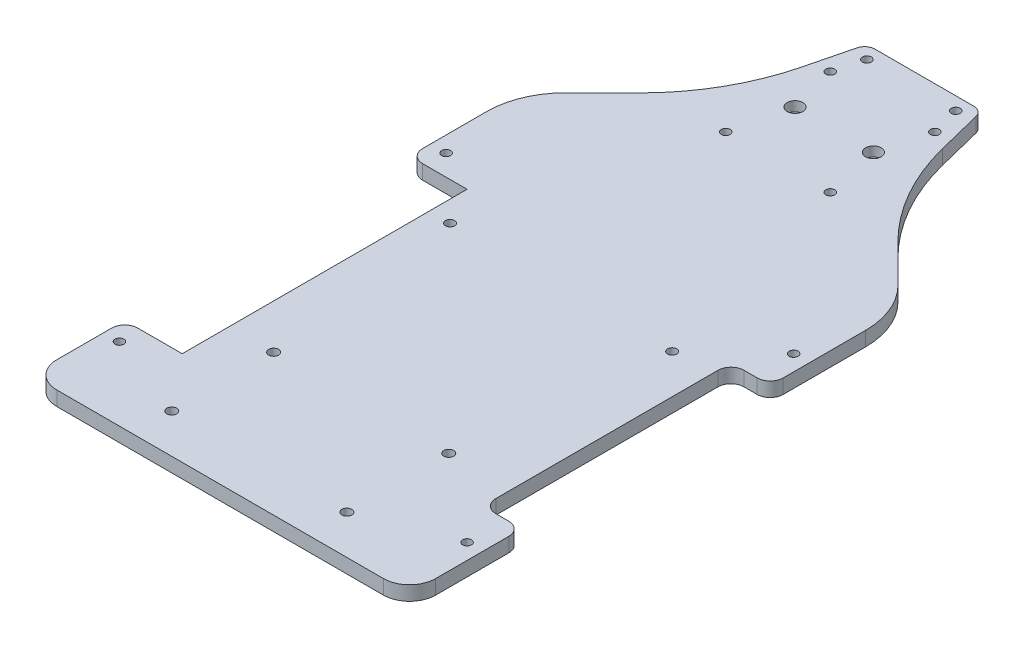
from build123d import *

# Parameters (mm, degrees)
DECK_BASE_DEPTH     = 5.5
BOLT_SLOT_REACH     = 7.5
SKETCH_3_R          = 1.7
FILLET_1_R          = 4
CUT_EXTRUDE_2_REACH = 7.5
SKETCH_11_W         = 22
SKETCH_11_H         = 109
SKETCH_11_W_2       = 15
SKETCH_11_H_2       = 95
CUT_EXTRUDE_1_REACH = 7.5
SKETCH_10_W         = 145
SKETCH_10_H         = 38.5
FILLET_2_R          = 10
FILLET_3_R          = 5
LIDAR_SLOT_REACH    = 7.5
SKETCH_4_R          = 1.7
VESC_SLOT_REACH     = 7.5
SKETCH_6_R          = 1.9
NANO_SLOT_REACH     = 7.5
SKETCH_7_R          = 1.75
CUT_EXTRUDE_3_REACH = 7.5
SKETCH_12_R         = 1.75
SKETCH_13_R         = 3
CUT_EXTRUDE_4_DEPTH = 3.7
CHAMFER_1_SIZE      = 4


with BuildPart() as part:
    # 스케치1 → Deck base (new body)
    with BuildSketch(Plane(origin=(0, 0, 0), x_dir=(1, 0, 0), z_dir=(0, 1, 0))):
        with BuildLine():
            Line((-72.5, 0), (-72.5, -180))
            ThreePointArc((-72.5, -180), (-69.571067812, -187.071067812), (-62.5, -190))
            Line((-62.5, -190), (-49.196112248, -190))
            ThreePointArc((-49.196112248, -190), (-47.589899161, -190.265015363), (-46.15395453, -191.031968194))
            Line((-46.15395453, -191.031968194), (-18.84604547, -211.968031806))
            ThreePointArc((-18.84604547, -211.968031806), (-17.410100839, -212.734984637), (-15.803887752, -213))
            Line((-15.803887752, -213), (15.803887752, -213))
            ThreePointArc((15.803887752, -213), (17.410100839, -212.734984637), (18.84604547, -211.968031806))
            Line((18.84604547, -211.968031806), (46.15395453, -191.031968194))
            ThreePointArc((46.15395453, -191.031968194), (47.589899161, -190.265015363), (49.196112248, -190))
            Line((49.196112248, -190), (62.5, -190))
            ThreePointArc((62.5, -190), (69.571067812, -187.071067812), (72.5, -180))
            Line((72.5, -180), (72.5, 0))
            ThreePointArc((72.5, 0), (70.204904333, 11.508182998), (63.670781605, 21.255540601))
            Line((63.670781605, 21.255540601), (49.478231298, 35.391496426))
            ThreePointArc((49.478231298, 35.391496426), (35.536990456, 53.662264501), (27, 75))
            Line((27, 75), (22, 95))
            Line((22, 95), (-22, 95))
            Line((-22, 95), (-27, 75))
            ThreePointArc((-27, 75), (-35.536990456, 53.662264501), (-49.478231298, 35.391496426))
            Line((-49.478231298, 35.391496426), (-63.670781605, 21.255540601))
            ThreePointArc((-63.670781605, 21.255540601), (-70.204904333, 11.508182998), (-72.5, 0))
        make_face()
    extrude(amount=DECK_BASE_DEPTH)

    # 스케치3 → Bolt slot (cut, up to next)
    with BuildSketch(Plane(origin=(0, 5.5, 0), x_dir=(1, 0, 0), z_dir=(0, 1, 0)), mode=Mode.PRIVATE) as bolt_slot_sk1:
        with Locations((17, 90)):
            Circle(SKETCH_3_R)
    bolt_slot_tool1 = extrude(bolt_slot_sk1.sketch, amount=-BOLT_SLOT_REACH, mode=Mode.PRIVATE) & part.part
    add(bolt_slot_tool1.solids().sort_by_distance((17, 5.5, -90))[0], mode=Mode.SUBTRACT)
    # 스케치3 → Bolt slot (cut, up to next)
    with BuildSketch(Plane(origin=(0, 5.5, 0), x_dir=(1, 0, 0), z_dir=(0, 1, 0)), mode=Mode.PRIVATE) as bolt_slot_sk2:
        with Locations((66.5, -146.5)):
            Circle(SKETCH_3_R)
    bolt_slot_tool2 = extrude(bolt_slot_sk2.sketch, amount=-BOLT_SLOT_REACH, mode=Mode.PRIVATE) & part.part
    add(bolt_slot_tool2.solids().sort_by_distance((66.5, 5.5, 146.5))[0], mode=Mode.SUBTRACT)
    # 스케치3 → Bolt slot (cut, up to next)
    with BuildSketch(Plane(origin=(0, 5.5, 0), x_dir=(1, 0, 0), z_dir=(0, 1, 0)), mode=Mode.PRIVATE) as bolt_slot_sk3:
        with Locations((66.5, -116.5)):
            Circle(SKETCH_3_R)
    bolt_slot_tool3 = extrude(bolt_slot_sk3.sketch, amount=-BOLT_SLOT_REACH, mode=Mode.PRIVATE) & part.part
    add(bolt_slot_tool3.solids().sort_by_distance((66.5, 5.5, 116.5))[0], mode=Mode.SUBTRACT)
    # 스케치3 → Bolt slot (cut, up to next)
    with BuildSketch(Plane(origin=(0, 5.5, 0), x_dir=(1, 0, 0), z_dir=(0, 1, 0)), mode=Mode.PRIVATE) as bolt_slot_sk4:
        with Locations((66.5, -51.5)):
            Circle(SKETCH_3_R)
    bolt_slot_tool4 = extrude(bolt_slot_sk4.sketch, amount=-BOLT_SLOT_REACH, mode=Mode.PRIVATE) & part.part
    add(bolt_slot_tool4.solids().sort_by_distance((66.5, 5.5, 51.5))[0], mode=Mode.SUBTRACT)
    # 스케치3 → Bolt slot (cut, up to next)
    with BuildSketch(Plane(origin=(0, 5.5, 0), x_dir=(1, 0, 0), z_dir=(0, 1, 0)), mode=Mode.PRIVATE) as bolt_slot_sk5:
        with Locations((66.5, -21.5)):
            Circle(SKETCH_3_R)
    bolt_slot_tool5 = extrude(bolt_slot_sk5.sketch, amount=-BOLT_SLOT_REACH, mode=Mode.PRIVATE) & part.part
    add(bolt_slot_tool5.solids().sort_by_distance((66.5, 5.5, 21.5))[0], mode=Mode.SUBTRACT)
    # 스케치3 → Bolt slot (cut, up to next)
    with BuildSketch(Plane(origin=(0, 5.5, 0), x_dir=(1, 0, 0), z_dir=(0, 1, 0)), mode=Mode.PRIVATE) as bolt_slot_sk6:
        with Locations((-66.5, -21.5)):
            Circle(SKETCH_3_R)
    bolt_slot_tool6 = extrude(bolt_slot_sk6.sketch, amount=-BOLT_SLOT_REACH, mode=Mode.PRIVATE) & part.part
    add(bolt_slot_tool6.solids().sort_by_distance((-66.5, 5.5, 21.5))[0], mode=Mode.SUBTRACT)
    # 스케치3 → Bolt slot (cut, up to next)
    with BuildSketch(Plane(origin=(0, 5.5, 0), x_dir=(1, 0, 0), z_dir=(0, 1, 0)), mode=Mode.PRIVATE) as bolt_slot_sk7:
        with Locations((-66.5, -51.5)):
            Circle(SKETCH_3_R)
    bolt_slot_tool7 = extrude(bolt_slot_sk7.sketch, amount=-BOLT_SLOT_REACH, mode=Mode.PRIVATE) & part.part
    add(bolt_slot_tool7.solids().sort_by_distance((-66.5, 5.5, 51.5))[0], mode=Mode.SUBTRACT)
    # 스케치3 → Bolt slot (cut, up to next)
    with BuildSketch(Plane(origin=(0, 5.5, 0), x_dir=(1, 0, 0), z_dir=(0, 1, 0)), mode=Mode.PRIVATE) as bolt_slot_sk8:
        with Locations((-66.5, -116.5)):
            Circle(SKETCH_3_R)
    bolt_slot_tool8 = extrude(bolt_slot_sk8.sketch, amount=-BOLT_SLOT_REACH, mode=Mode.PRIVATE) & part.part
    add(bolt_slot_tool8.solids().sort_by_distance((-66.5, 5.5, 116.5))[0], mode=Mode.SUBTRACT)
    # 스케치3 → Bolt slot (cut, up to next)
    with BuildSketch(Plane(origin=(0, 5.5, 0), x_dir=(1, 0, 0), z_dir=(0, 1, 0)), mode=Mode.PRIVATE) as bolt_slot_sk9:
        with Locations((-66.5, -146.5)):
            Circle(SKETCH_3_R)
    bolt_slot_tool9 = extrude(bolt_slot_sk9.sketch, amount=-BOLT_SLOT_REACH, mode=Mode.PRIVATE) & part.part
    add(bolt_slot_tool9.solids().sort_by_distance((-66.5, 5.5, 146.5))[0], mode=Mode.SUBTRACT)
    # 스케치3 → Bolt slot (cut, up to next)
    with BuildSketch(Plane(origin=(0, 5.5, 0), x_dir=(1, 0, 0), z_dir=(0, 1, 0)), mode=Mode.PRIVATE) as bolt_slot_sk10:
        with Locations((-17, 90)):
            Circle(SKETCH_3_R)
    bolt_slot_tool10 = extrude(bolt_slot_sk10.sketch, amount=-BOLT_SLOT_REACH, mode=Mode.PRIVATE) & part.part
    add(bolt_slot_tool10.solids().sort_by_distance((-17, 5.5, -90))[0], mode=Mode.SUBTRACT)

    # 필렛1
    fillet_1_edges = [part.edges().sort_by_distance(p)[0] for p in [
        (22, 2.75, -95),
        (-22, 2.75, -95),
    ]]
    fillet(fillet_1_edges, radius=FILLET_1_R)

    # 스케치11 → 컷-돌출2 (cut, up to next)
    with BuildSketch(Plane(origin=(0, 5.5, 0), x_dir=(1, 0, 0), z_dir=(0, 1, 0)), mode=Mode.PRIVATE) as cut_extrude_2_sk1:
        with Locations((-61.5, -84)):
            Rectangle(SKETCH_11_W, SKETCH_11_H)
    cut_extrude_2_tool1 = extrude(cut_extrude_2_sk1.sketch, amount=-CUT_EXTRUDE_2_REACH, mode=Mode.PRIVATE) & part.part
    add(cut_extrude_2_tool1.solids().sort_by_distance((-61.5, 5.5, 84))[0], mode=Mode.SUBTRACT)
    # 스케치11 → 컷-돌출2 (cut, up to next)
    with BuildSketch(Plane(origin=(0, 5.5, 0), x_dir=(1, 0, 0), z_dir=(0, 1, 0)), mode=Mode.PRIVATE) as cut_extrude_2_sk2:
        with Locations((65, -84)):
            Rectangle(SKETCH_11_W_2, SKETCH_11_H_2)
    cut_extrude_2_tool2 = extrude(cut_extrude_2_sk2.sketch, amount=-CUT_EXTRUDE_2_REACH, mode=Mode.PRIVATE) & part.part
    add(cut_extrude_2_tool2.solids().sort_by_distance((65, 5.5, 84))[0], mode=Mode.SUBTRACT)

    # 스케치10 → 컷-돌출1 (cut, up to next)
    with BuildSketch(Plane(origin=(0, 5.5, 0), x_dir=(1, 0, 0), z_dir=(0, 1, 0)), mode=Mode.PRIVATE) as cut_extrude_1_sk1:
        with Locations((0, -193.75)):
            Rectangle(SKETCH_10_W, SKETCH_10_H)
    cut_extrude_1_tool1 = extrude(cut_extrude_1_sk1.sketch, amount=-CUT_EXTRUDE_1_REACH, mode=Mode.PRIVATE) & part.part
    add(cut_extrude_1_tool1.solids().sort_by_distance((0, 5.5, 193.75))[0], mode=Mode.SUBTRACT)

    # 필렛2
    fillet_2_edges = [part.edges().sort_by_distance(p)[0] for p in [
        (72.5, 2.75, 174.5),
        (-72.5, 2.75, 174.5),
    ]]
    fillet(fillet_2_edges, radius=FILLET_2_R)

    # 필렛3
    fillet_3_edges = [part.edges().sort_by_distance(p)[0] for p in [
        (-72.5, 2.75, 138.5),
        (-72.5, 2.75, 29.5),
        (72.5, 2.75, 36.5),
        (72.5, 2.75, 131.5),
        (57.5, 2.75, 131.5),
        (57.5, 2.75, 36.5),
    ]]
    fillet(fillet_3_edges, radius=FILLET_3_R)

    # 스케치4 → Lidar slot (cut, up to next)
    with BuildSketch(Plane(origin=(0, 5.5, 0), x_dir=(1, 0, 0), z_dir=(0, 1, 0)), mode=Mode.PRIVATE) as lidar_slot_sk1:
        with Locations((-20, 79)):
            Circle(SKETCH_4_R)
    lidar_slot_tool1 = extrude(lidar_slot_sk1.sketch, amount=-LIDAR_SLOT_REACH, mode=Mode.PRIVATE) & part.part
    add(lidar_slot_tool1.solids().sort_by_distance((-20, 5.5, -79))[0], mode=Mode.SUBTRACT)
    # 스케치4 → Lidar slot (cut, up to next)
    with BuildSketch(Plane(origin=(0, 5.5, 0), x_dir=(1, 0, 0), z_dir=(0, 1, 0)), mode=Mode.PRIVATE) as lidar_slot_sk2:
        with Locations((-20, 39)):
            Circle(SKETCH_4_R)
    lidar_slot_tool2 = extrude(lidar_slot_sk2.sketch, amount=-LIDAR_SLOT_REACH, mode=Mode.PRIVATE) & part.part
    add(lidar_slot_tool2.solids().sort_by_distance((-20, 5.5, -39))[0], mode=Mode.SUBTRACT)
    # 스케치4 → Lidar slot (cut, up to next)
    with BuildSketch(Plane(origin=(0, 5.5, 0), x_dir=(1, 0, 0), z_dir=(0, 1, 0)), mode=Mode.PRIVATE) as lidar_slot_sk3:
        with Locations((20, 39)):
            Circle(SKETCH_4_R)
    lidar_slot_tool3 = extrude(lidar_slot_sk3.sketch, amount=-LIDAR_SLOT_REACH, mode=Mode.PRIVATE) & part.part
    add(lidar_slot_tool3.solids().sort_by_distance((20, 5.5, -39))[0], mode=Mode.SUBTRACT)
    # 스케치4 → Lidar slot (cut, up to next)
    with BuildSketch(Plane(origin=(0, 5.5, 0), x_dir=(1, 0, 0), z_dir=(0, 1, 0)), mode=Mode.PRIVATE) as lidar_slot_sk4:
        with Locations((20, 79)):
            Circle(SKETCH_4_R)
    lidar_slot_tool4 = extrude(lidar_slot_sk4.sketch, amount=-LIDAR_SLOT_REACH, mode=Mode.PRIVATE) & part.part
    add(lidar_slot_tool4.solids().sort_by_distance((20, 5.5, -79))[0], mode=Mode.SUBTRACT)

    # 스케치6 → Vesc slot (cut, up to next)
    with BuildSketch(Plane(origin=(0, 5.5, 0), x_dir=(1, 0, 0), z_dir=(0, 1, 0)), mode=Mode.PRIVATE) as vesc_slot_sk1:
        with Locations((33.5, -120.5)):
            Circle(SKETCH_6_R)
    vesc_slot_tool1 = extrude(vesc_slot_sk1.sketch, amount=-VESC_SLOT_REACH, mode=Mode.PRIVATE) & part.part
    add(vesc_slot_tool1.solids().sort_by_distance((33.5, 5.5, 120.5))[0], mode=Mode.SUBTRACT)
    # 스케치6 → Vesc slot (cut, up to next)
    with BuildSketch(Plane(origin=(0, 5.5, 0), x_dir=(1, 0, 0), z_dir=(0, 1, 0)), mode=Mode.PRIVATE) as vesc_slot_sk2:
        with Locations((33.5, -159.5)):
            Circle(SKETCH_6_R)
    vesc_slot_tool2 = extrude(vesc_slot_sk2.sketch, amount=-VESC_SLOT_REACH, mode=Mode.PRIVATE) & part.part
    add(vesc_slot_tool2.solids().sort_by_distance((33.5, 5.5, 159.5))[0], mode=Mode.SUBTRACT)
    # 스케치6 → Vesc slot (cut, up to next)
    with BuildSketch(Plane(origin=(0, 5.5, 0), x_dir=(1, 0, 0), z_dir=(0, 1, 0)), mode=Mode.PRIVATE) as vesc_slot_sk3:
        with Locations((-33.5, -159.5)):
            Circle(SKETCH_6_R)
    vesc_slot_tool3 = extrude(vesc_slot_sk3.sketch, amount=-VESC_SLOT_REACH, mode=Mode.PRIVATE) & part.part
    add(vesc_slot_tool3.solids().sort_by_distance((-33.5, 5.5, 159.5))[0], mode=Mode.SUBTRACT)
    # 스케치6 → Vesc slot (cut, up to next)
    with BuildSketch(Plane(origin=(0, 5.5, 0), x_dir=(1, 0, 0), z_dir=(0, 1, 0)), mode=Mode.PRIVATE) as vesc_slot_sk4:
        with Locations((-33.5, -120.5)):
            Circle(SKETCH_6_R)
    vesc_slot_tool4 = extrude(vesc_slot_sk4.sketch, amount=-VESC_SLOT_REACH, mode=Mode.PRIVATE) & part.part
    add(vesc_slot_tool4.solids().sort_by_distance((-33.5, 5.5, 120.5))[0], mode=Mode.SUBTRACT)

    # 스케치7 → Nano slot (cut, up to next)
    with BuildSketch(Plane(origin=(0, 5.5, 0), x_dir=(1, 0, 0), z_dir=(0, 1, 0)), mode=Mode.PRIVATE) as nano_slot_sk1:
        with Locations((-42.5, -44)):
            Circle(SKETCH_7_R)
    nano_slot_tool1 = extrude(nano_slot_sk1.sketch, amount=-NANO_SLOT_REACH, mode=Mode.PRIVATE) & part.part
    add(nano_slot_tool1.solids().sort_by_distance((-42.5, 5.5, 44))[0], mode=Mode.SUBTRACT)
    # 스케치7 → Nano slot (cut, up to next)
    with BuildSketch(Plane(origin=(0, 5.5, 0), x_dir=(1, 0, 0), z_dir=(0, 1, 0)), mode=Mode.PRIVATE) as nano_slot_sk2:
        with Locations((42.5, -44)):
            Circle(SKETCH_7_R)
    nano_slot_tool2 = extrude(nano_slot_sk2.sketch, amount=-NANO_SLOT_REACH, mode=Mode.PRIVATE) & part.part
    add(nano_slot_tool2.solids().sort_by_distance((42.5, 5.5, 44))[0], mode=Mode.SUBTRACT)

    # 스케치12 → 컷-돌출3 (cut, up to next)
    with BuildSketch(Plane(origin=(0, 5.5, 0), x_dir=(1, 0, 0), z_dir=(0, 1, 0)), mode=Mode.PRIVATE) as cut_extrude_3_sk1:
        with Locations((-15, 60.5)):
            Circle(SKETCH_12_R)
    cut_extrude_3_tool1 = extrude(cut_extrude_3_sk1.sketch, amount=-CUT_EXTRUDE_3_REACH, mode=Mode.PRIVATE) & part.part
    add(cut_extrude_3_tool1.solids().sort_by_distance((-15, 5.5, -60.5))[0], mode=Mode.SUBTRACT)
    # 스케치12 → 컷-돌출3 (cut, up to next)
    with BuildSketch(Plane(origin=(0, 5.5, 0), x_dir=(1, 0, 0), z_dir=(0, 1, 0)), mode=Mode.PRIVATE) as cut_extrude_3_sk2:
        with Locations((15, 60.5)):
            Circle(SKETCH_12_R)
    cut_extrude_3_tool2 = extrude(cut_extrude_3_sk2.sketch, amount=-CUT_EXTRUDE_3_REACH, mode=Mode.PRIVATE) & part.part
    add(cut_extrude_3_tool2.solids().sort_by_distance((15, 5.5, -60.5))[0], mode=Mode.SUBTRACT)

    # 스케치13 → 컷-돌출4 (cut)
    with BuildSketch(Plane(origin=(0, 5.5, 0), x_dir=(1, 0, 0), z_dir=(0, 1, 0))):
        with Locations((-15, 60.5)):
            Circle(SKETCH_13_R)
        with Locations((15, 60.5)):
            Circle(SKETCH_13_R)
    extrude(amount=-CUT_EXTRUDE_4_DEPTH, mode=Mode.SUBTRACT)

    # 모따기1
    chamfer_1_edges = [part.edges().sort_by_distance(p)[0] for p in [
        (-50.5, 0, 84),
    ]]
    chamfer(chamfer_1_edges, length=CHAMFER_1_SIZE)


solid = part.part
